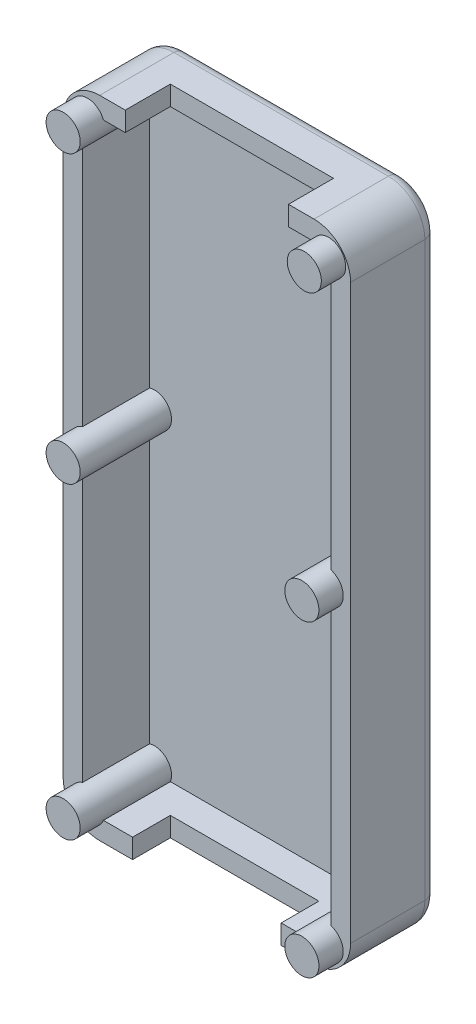
from build123d import *

# Parameters (mm, degrees)
SKETCH1_W                = 23.6
SKETCH1_H                = 53
BOSS_EXTRUDE2_DEPTH      = 7.1
SHELL1_T                 = -1.6
FILLET2_R                = 3
SKETCH7_W                = 12.2
SKETCH7_H                = 1.6
CUT_EXTRUDE1_DEPTH       = 3.1
SKETCH8_W                = 13.4
SKETCH8_H                = 1.6
CUT_EXTRUDE2_DEPTH       = 3.7
FILLET3_R                = 1
SKETCH10_R               = 1.4
BOSS_EXTRUDE4_DEPTH      = 2
BOSS_EXTRUDE4_DEPTH_BACK = 6.5


with BuildPart() as part:
    # Sketch1 → Boss-Extrude2 (new body)
    with BuildSketch(Plane.XY):
        with Locations((-28.818351302, -28.026390465)):
            Rectangle(SKETCH1_W, SKETCH1_H)
    extrude(amount=BOSS_EXTRUDE2_DEPTH)

    # Shell1
    shell1_openings = [part.faces().sort_by_distance(p)[0] for p in [
        (-28.818351302, -28.026390465, 7.1),
    ]]
    offset(amount=SHELL1_T, openings=shell1_openings, kind=Kind.INTERSECTION)

    # Fillet2
    fillet2_edges = [part.edges().sort_by_distance(p)[0] for p in [
        (-40.618351302, -1.526390465, 3.55),
        (-17.018351302, -1.526390465, 3.55),
        (-17.018351302, -54.526390465, 3.55),
        (-40.618351302, -54.526390465, 3.55),
    ]]
    fillet(fillet2_edges, radius=FILLET2_R)

    # Sketch7 → Cut-Extrude1 (cut)
    with BuildSketch(Plane.XY.offset(7.1)):
        with Locations((-28.818351302, -53.726390465)):
            Rectangle(SKETCH7_W, SKETCH7_H)
    extrude(amount=-CUT_EXTRUDE1_DEPTH, mode=Mode.SUBTRACT)

    # Sketch8 → Cut-Extrude2 (cut)
    with BuildSketch(Plane.XY.offset(7.1)):
        with Locations((-28.818351302, -2.326390465)):
            Rectangle(SKETCH8_W, SKETCH8_H)
    extrude(amount=-CUT_EXTRUDE2_DEPTH, mode=Mode.SUBTRACT)

    # Fillet3
    fillet3_edges = [part.edges().sort_by_distance(p)[0] for p in [
        (-28.818351302, -1.526390465, 0),
        (-40.618351302, -28.026390465, 0),
        (-17.018351302, -28.026390465, 0),
        (-28.818351302, -54.526390465, 0),
        (-39.739671646, -2.405070122, 0),
        (-39.739671646, -53.647710809, 0),
        (-17.897030959, -53.647710809, 0),
        (-17.897030959, -2.405070122, 0),
    ]]
    fillet(fillet3_edges, radius=FILLET3_R)

    # Sketch10 → Boss-Extrude4 (add, two sides)
    with BuildSketch(Plane.XY.offset(7.1)) as boss_extrude4_sk:
        with Locations((-38.618351302, -52.426390465)):
            Circle(SKETCH10_R)
        with Locations((-19.018351302, -52.426390465)):
            Circle(SKETCH10_R)
        with Locations((-38.618351302, -27.126390465)):
            Circle(SKETCH10_R)
        with Locations((-19.018351302, -27.126390465)):
            Circle(SKETCH10_R)
        with Locations((-18.818351302, -3.626390465)):
            Circle(SKETCH10_R)
        with Locations((-38.618351302, -3.626390465)):
            Circle(SKETCH10_R)
    extrude(amount=BOSS_EXTRUDE4_DEPTH)
    extrude(boss_extrude4_sk.sketch, amount=-BOSS_EXTRUDE4_DEPTH_BACK)


solid = part.part
